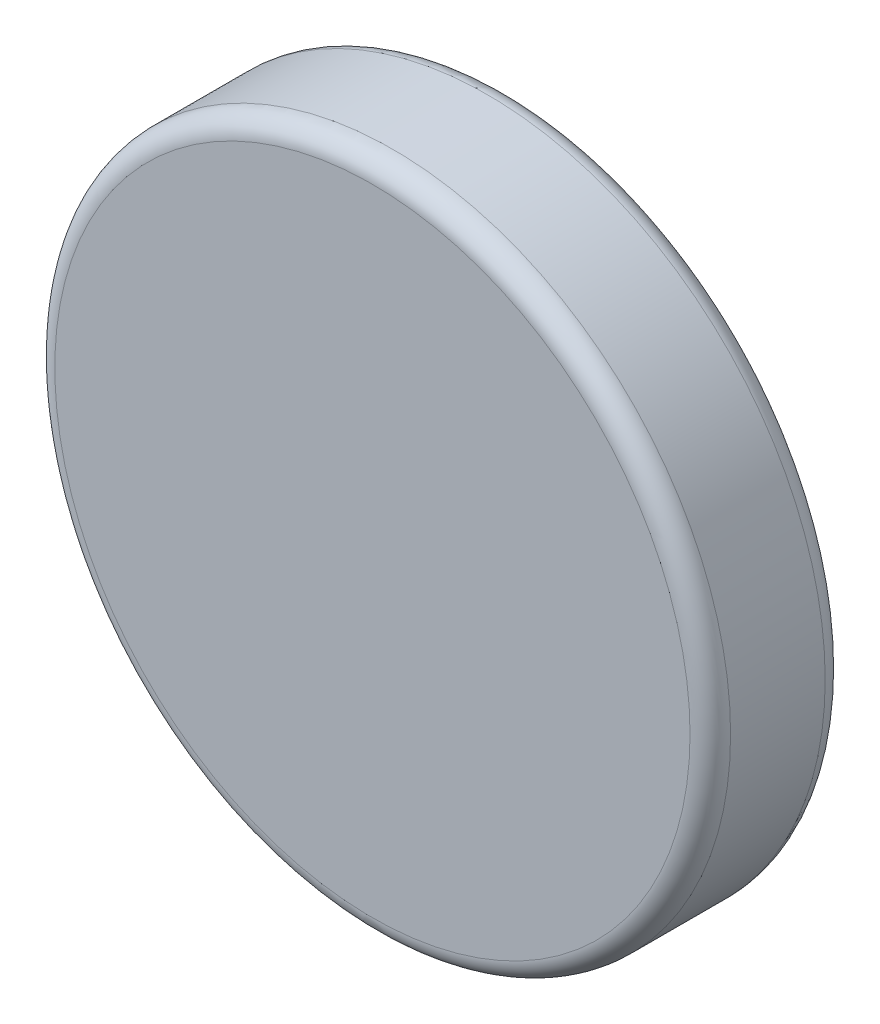
from build123d import *

# Parameters (mm, degrees)
ESQUISSE1_R        = 5
BOSS_EXTRU_1_DEPTH = 2
CONG_1_R           = 0.3


with BuildPart() as part:
    # Esquisse1 → Boss.-Extru.1 (new body)
    with BuildSketch(Plane.XY):
        Circle(ESQUISSE1_R)
    extrude(amount=BOSS_EXTRU_1_DEPTH)

    # Congé1
    cong_1_edges = [part.edges().sort_by_distance(p)[0] for p in [
        (-5, 0, 0),
        (-5, 0, 2),
    ]]
    fillet(cong_1_edges, radius=CONG_1_R)


solid = part.part
